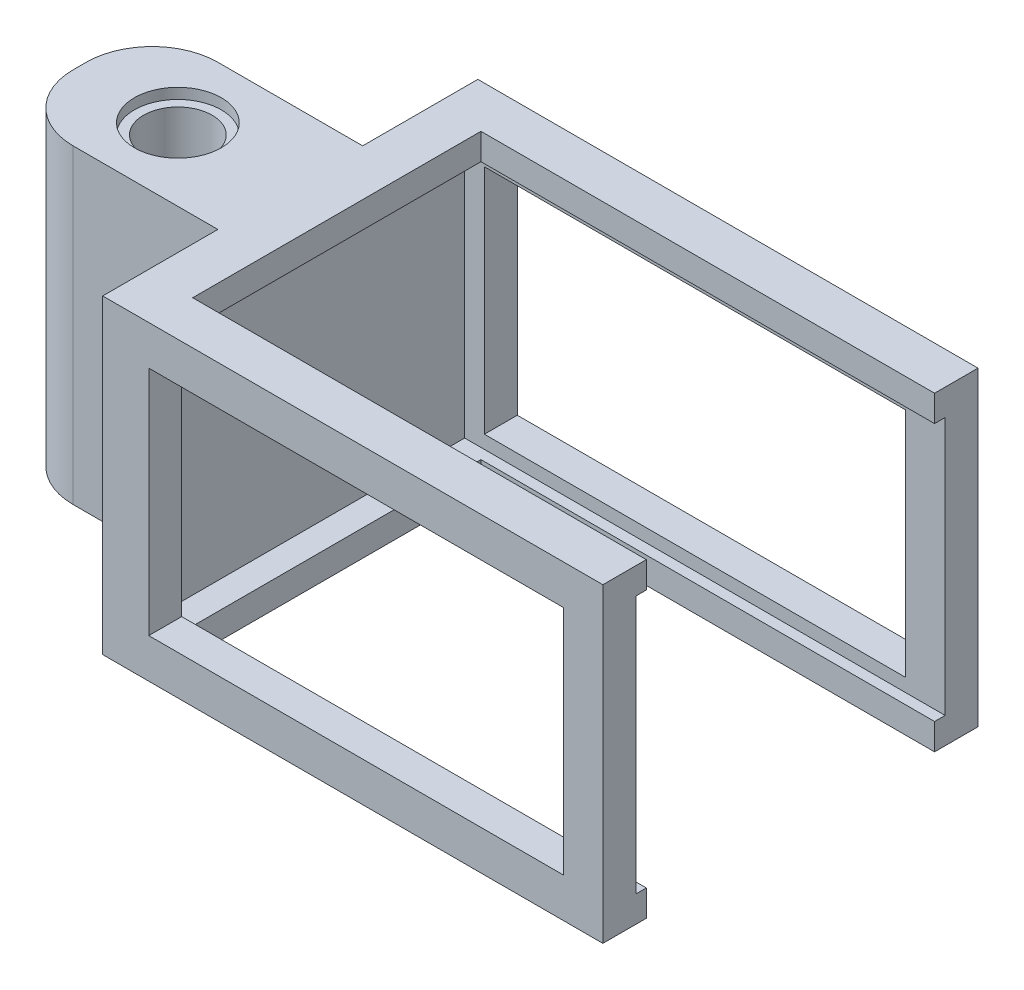
from build123d import *

# Parameters (mm, degrees)
SKETCH2_W            = 38
SKETCH2_H            = 23.6
BOSS_EXTRUDE2_DEPTH  = 2.5
SKETCH3_W            = 35
SKETCH3_H            = 17.6
CUT_EXTRUDE2_DEPTH   = 2.5
SKETCH5_W            = 36.5
SKETCH5_H            = 2
SKETCH5_W_2          = 1.5
SKETCH5_H_2          = 19.6
BOSS_EXTRUDE3_DEPTH  = 26
SKETCH7_W            = 36.5
SKETCH7_H            = 2.5
BOSS_EXTRUDE5_DEPTH  = 1
SKETCH10_W           = 12.597499818
SKETCH10_H           = 2.5
SKETCH10_W_2         = 23.902500182
BOSS_EXTRUDE6_DEPTH  = 1
SKETCH11_W           = 2.5
SKETCH11_H           = 17.6
BOSS_EXTRUDE7_DEPTH  = 2
SKETCH15_W           = 30.589508609
SKETCH15_H           = 23.5
SKETCH15_W_2         = 3.8732763
CUT_EXTRUDE4_DEPTH   = 30
SKETCH16_W           = 3
SKETCH16_H           = 2.5
BOSS_EXTRUDE8_DEPTH  = 20
SKETCH17_W           = 3
SKETCH17_H           = 2.5
BOSS_EXTRUDE9_DEPTH  = 20
SKETCH19_W           = 5.5
SKETCH19_H           = 23.6
BOSS_EXTRUDE10_DEPTH = 16
SKETCH20_R           = 2.6
CUT_EXTRUDE6_DEPTH   = 30
SKETCH21_R           = 3.3
CUT_EXTRUDE7_DEPTH   = 0.8
SKETCH22_R           = 3.3
CUT_EXTRUDE8_DEPTH   = 0.8
FILLET1_R            = 5
FILLET3_R            = 5
SKETCH23_W           = 34.462784909
SKETCH23_H           = 2
BOSS_EXTRUDE11_DEPTH = 0.8
SKETCH24_W           = 34.462784909
SKETCH24_H           = 2
BOSS_EXTRUDE12_DEPTH = 0.8
SKETCH25_W           = 34.462784909
SKETCH25_H           = 2
BOSS_EXTRUDE13_DEPTH = 0.8
SKETCH26_W           = 34.462784909
SKETCH26_H           = 2
BOSS_EXTRUDE14_DEPTH = 0.8


with BuildPart() as part:
    # Sketch2 → Boss-Extrude2 (new body)
    with BuildSketch(Plane.XY):
        with Locations((19, 11.8)):
            Rectangle(SKETCH2_W, SKETCH2_H)
    extrude(amount=BOSS_EXTRUDE2_DEPTH)

    # Sketch3 → Cut-Extrude2 (cut)
    with BuildSketch(Plane.XY.offset(2.5)):
        with Locations((20.5, 11.8)):
            Rectangle(SKETCH3_W, SKETCH3_H)
    extrude(amount=-CUT_EXTRUDE2_DEPTH, mode=Mode.SUBTRACT)

    # Sketch5 → Boss-Extrude3 (add)
    with BuildSketch(Plane.XY.offset(2.5)):
        with Locations((19.75, 22.6)):
            Rectangle(SKETCH5_W, SKETCH5_H)
        with Locations((0.75, 22.6)):
            Rectangle(SKETCH5_W_2, SKETCH5_H)
        with Locations((0.75, 11.8)):
            Rectangle(SKETCH5_W_2, SKETCH5_H_2)
        with Locations((0.75, 1)):
            Rectangle(SKETCH5_W_2, SKETCH5_H)
        with Locations((19.75, 1)):
            Rectangle(SKETCH5_W, SKETCH5_H)
    extrude(amount=BOSS_EXTRUDE3_DEPTH)

    # Sketch7 → Boss-Extrude5 (add)
    with BuildSketch(Plane(origin=(0, 2, 0), x_dir=(1, 0, 0), z_dir=(0, 1, 0))):
        with Locations((19.75, -27.25)):
            Rectangle(SKETCH7_W, SKETCH7_H)
    extrude(amount=BOSS_EXTRUDE5_DEPTH)

    # Sketch10 → Boss-Extrude6 (add)
    with BuildSketch(Plane.XZ.offset(-21.6)):
        with Locations((31.701250091, 27.25)):
            Rectangle(SKETCH10_W, SKETCH10_H)
        with Locations((13.451250091, 27.25)):
            Rectangle(SKETCH10_W_2, SKETCH10_H)
    extrude(amount=BOSS_EXTRUDE6_DEPTH)

    # Sketch11 → Boss-Extrude7 (add)
    with BuildSketch(Plane(origin=(1.5, 0, 0), x_dir=(0, 0, -1), z_dir=(1, 0, 0))):
        with Locations((-27.25, 11.8)):
            Rectangle(SKETCH11_W, SKETCH11_H)
    extrude(amount=BOSS_EXTRUDE7_DEPTH)

    # Sketch15 → Cut-Extrude4 (cut)
    with BuildSketch(Plane(origin=(0, 23.6, 0), x_dir=(1, 0, 0), z_dir=(0, 1, 0))):
        with Locations((18.831969395, -14.25)):
            Rectangle(SKETCH15_W, SKETCH15_H)
        with Locations((36.06336185, -14.25)):
            Rectangle(SKETCH15_W_2, SKETCH15_H)
    extrude(amount=-CUT_EXTRUDE4_DEPTH, mode=Mode.SUBTRACT)

    # Sketch16 → Boss-Extrude8 (add)
    with BuildSketch(Plane(origin=(0, 3, 0), x_dir=(1, 0, 0), z_dir=(0, 1, 0))):
        with Locations((36.5, -1.25)):
            Rectangle(SKETCH16_W, SKETCH16_H)
    extrude(amount=BOSS_EXTRUDE8_DEPTH)

    # Sketch17 → Boss-Extrude9 (add)
    with BuildSketch(Plane(origin=(0, 3, 0), x_dir=(1, 0, 0), z_dir=(0, 1, 0))):
        with Locations((36.5, -27.25)):
            Rectangle(SKETCH17_W, SKETCH17_H)
    extrude(amount=BOSS_EXTRUDE9_DEPTH)

    # Sketch19 → Boss-Extrude10 (add)
    with BuildSketch(Plane.ZY):
        with Locations((17, 11.8)):
            Rectangle(SKETCH19_W, SKETCH19_H)
        with Locations((11.5, 11.8)):
            Rectangle(SKETCH19_W, SKETCH19_H)
    extrude(amount=BOSS_EXTRUDE10_DEPTH)

    # Sketch20 → Cut-Extrude6 (cut)
    with BuildSketch(Plane(origin=(0, 23.6, 0), x_dir=(1, 0, 0), z_dir=(0, 1, 0))):
        with Locations((-8.54, -14.25)):
            Circle(SKETCH20_R)
    extrude(amount=-CUT_EXTRUDE6_DEPTH, mode=Mode.SUBTRACT)

    # Sketch21 → Cut-Extrude7 (cut)
    with BuildSketch(Plane(origin=(0, 23.6, 0), x_dir=(1, 0, 0), z_dir=(0, 1, 0))):
        with Locations((-8.54, -14.25)):
            Circle(SKETCH21_R)
    extrude(amount=-CUT_EXTRUDE7_DEPTH, mode=Mode.SUBTRACT)

    # Sketch22 → Cut-Extrude8 (cut)
    with BuildSketch(Plane.XZ):
        with Locations((-8.54, 14.25)):
            Circle(SKETCH22_R)
    extrude(amount=-CUT_EXTRUDE8_DEPTH, mode=Mode.SUBTRACT)

    # Fillet1
    fillet1_edges = [part.edges().sort_by_distance(p)[0] for p in [
        (-16, 11.8, 8.75),
    ]]
    fillet(fillet1_edges, radius=FILLET1_R)

    # Fillet3
    fillet3_edges = [part.edges().sort_by_distance(p)[0] for p in [
        (-16, 11.8, 19.75),
    ]]
    fillet(fillet3_edges, radius=FILLET3_R)

    # Sketch23 → Boss-Extrude11 (add)
    with BuildSketch(Plane(origin=(0, 0, 26), x_dir=(-1, 0, 0), z_dir=(0, 0, -1))):
        with Locations((-20.768607546, 22.6)):
            Rectangle(SKETCH23_W, SKETCH23_H)
    extrude(amount=BOSS_EXTRUDE11_DEPTH)

    # Sketch24 → Boss-Extrude12 (add)
    with BuildSketch(Plane.XY.offset(2.5)):
        with Locations((20.768607546, 22.6)):
            Rectangle(SKETCH24_W, SKETCH24_H)
    extrude(amount=BOSS_EXTRUDE12_DEPTH)

    # Sketch25 → Boss-Extrude13 (add)
    with BuildSketch(Plane(origin=(0, 0, 26), x_dir=(-1, 0, 0), z_dir=(0, 0, -1))):
        with Locations((-20.768607546, 1)):
            Rectangle(SKETCH25_W, SKETCH25_H)
    extrude(amount=BOSS_EXTRUDE13_DEPTH)

    # Sketch26 → Boss-Extrude14 (add)
    with BuildSketch(Plane.XY.offset(2.5)):
        with Locations((20.768607546, 1)):
            Rectangle(SKETCH26_W, SKETCH26_H)
    extrude(amount=BOSS_EXTRUDE14_DEPTH)


solid = part.part
